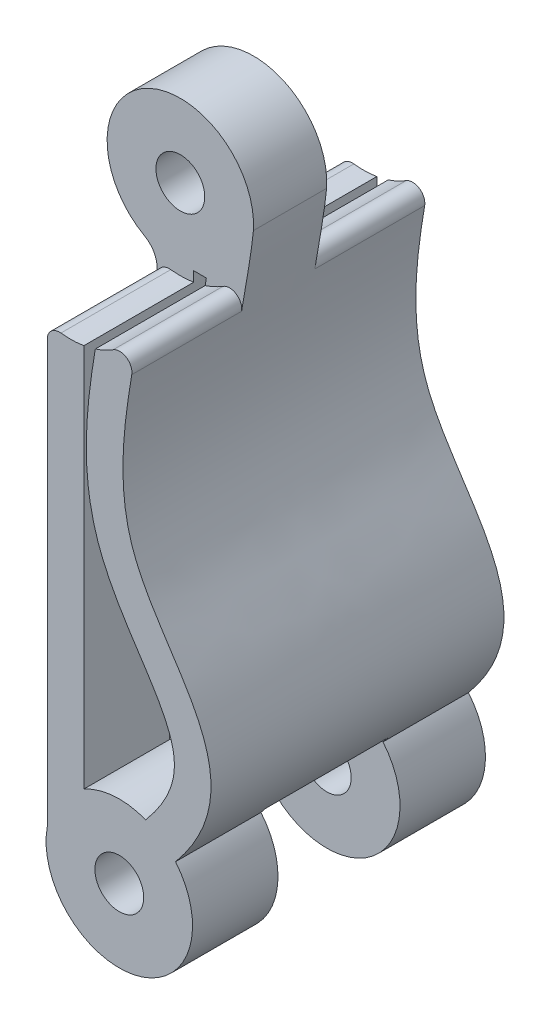
from build123d import *

# Parameters (mm, degrees)
SKETCH1_R               = 1
BOSS_EXTRUDE1_DEPTH     = 12
SKETCH2_R               = 3.3
CUT_EXTRUDE1_DEPTH      = 4.5
SKETCH3_R               = 3.3
CUT_EXTRUDE2_DEPTH      = 2.5
CUT_EXTRUDE2_DEPTH_BACK = 2.5
FILLET1_R               = 0.5
FILLET2_R               = 1


with BuildPart() as part:
    # Sketch1 → Boss-Extrude1 (new body)
    with BuildSketch(Plane.XY):
        with BuildLine():
            Line((-2.048815827, 41.884151299), (-2.048815827, 23.656682303))
            ThreePointArc((-2.048815827, 23.656682303), (1.66754925, 20.218418642), (3.205412143, 25.042110601))
            add(Edge.make_bspline(
                [(1.896008332, 44.529660516), (1.616069448, 41.758878479), (-0.936917255, 33.955197005), (6.844694938, 29.417505011), (3.205412143, 25.042110601)],
                knots=[0, 0, 0, 0, 0.461184527, 1, 1, 1, 1], degree=3))
            ThreePointArc((1.896008332, 44.529660516), (-2.768270934, 47.220856283), (-2.048815827, 41.884151299))
        make_face()
        with Locations((-1.097343641, 44.729270045)):
            Circle(SKETCH1_R, mode=Mode.SUBTRACT)
        with Locations((0.902656359, 23.119270045)):
            Circle(SKETCH1_R, mode=Mode.SUBTRACT)
        with BuildLine():
            Line((-0.031319306, 41.884151299), (-0.548815827, 41.884151299))
            Line((-0.548815827, 41.884151299), (-0.548815827, 25.744765902))
            ThreePointArc((-0.548815827, 25.744765902), (0.697826573, 26.112269337), (1.982912704, 25.918028026))
            add(Edge.make_bspline(
                [(-0.031319306, 41.884151299), (-0.050798368, 41.769911378), (-0.110231132, 41.41757497), (-0.243210983, 40.585051968), (-0.402027872, 39.353261852), (-0.479087992, 37.828213551), (-0.375856847, 36.275358456), (0.009969142, 34.681069755), (0.941317901, 32.770668216), (2.035404053, 31.246938586), (2.80471042, 29.909471533), (3.128629571, 29.030940173), (3.19641087, 28.267404516), (3.032335606, 27.550309668), (2.666289508, 26.829120101), (2.334869511, 26.350170873), (2.106769915, 26.067173099), (2.026097439, 25.969974031), (1.996829195, 25.934759382), (1.982912704, 25.918028026)],
                knots=[0.149200089, 0.149200089, 0.149200089, 0.149200089, 0.165683382, 0.19960026, 0.265533433, 0.331466606, 0.397399778, 0.463332951, 0.529266124, 0.661132469, 0.727065642, 0.792998815, 0.858931987, 0.92486516, 0.957831746, 0.990798333, 0.999039979, 1.001358499, 1.00341891, 1.00341891, 1.00341891, 1.00341891], degree=3))
        make_face(mode=Mode.SUBTRACT)
    extrude(amount=BOSS_EXTRUDE1_DEPTH)

    # Sketch2 → Cut-Extrude1 (cut)
    with BuildSketch(Plane.XY.offset(12)):
        with Locations((-1.097343641, 44.729270045)):
            Circle(SKETCH2_R)
    cut_extrude1 = extrude(amount=-CUT_EXTRUDE1_DEPTH, mode=Mode.SUBTRACT)

    # Mirror1: Cut-Extrude1 across plane
    add(cut_extrude1.mirror(Plane.XY.offset(6)), mode=Mode.SUBTRACT)

    # Sketch3 → Cut-Extrude2 (cut, two sides)
    with BuildSketch(Plane.XY.offset(6)) as cut_extrude2_sk:
        with Locations((0.902656359, 23.119270045)):
            Circle(SKETCH3_R)
    extrude(amount=CUT_EXTRUDE2_DEPTH, mode=Mode.SUBTRACT)
    extrude(cut_extrude2_sk.sketch, amount=-CUT_EXTRUDE2_DEPTH_BACK, mode=Mode.SUBTRACT)

    # Fillet1
    fillet1_edges = [part.edges().sort_by_distance(p)[0] for p in [
        (1.670824854, 42.932817101, 9.75),
        (-2.048815827, 41.569412346, 9.75),
        (1.670824854, 42.932817101, 2.25),
        (-2.048815827, 41.569412346, 2.25),
    ]]
    fillet(fillet1_edges, radius=FILLET1_R)

    # Fillet2
    fillet2_edges = [part.edges().sort_by_distance(p)[0] for p in [
        (-2.048815827, 41.884151299, 6),
    ]]
    fillet(fillet2_edges, radius=FILLET2_R)


solid = part.part
